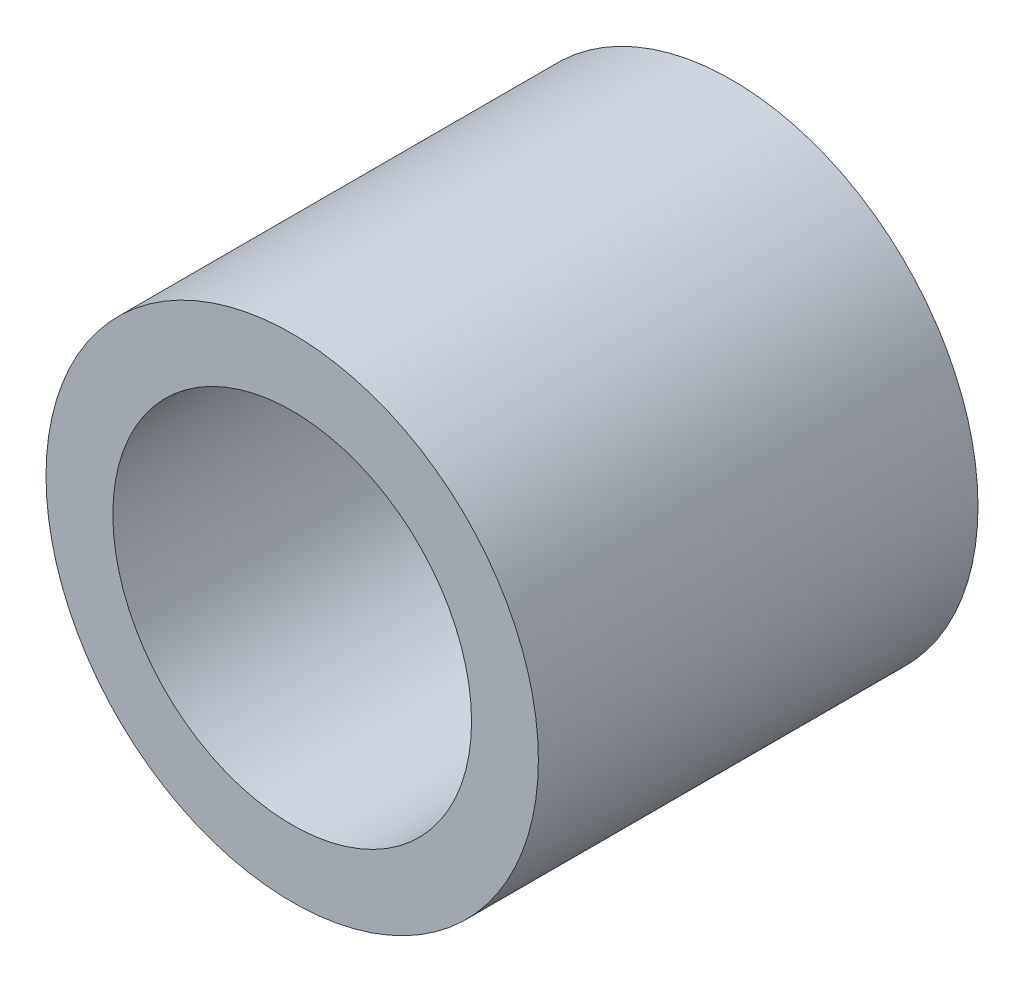
from build123d import *

# Parameters (mm, degrees)
SKETCH_1_R      = 14
SKETCH_1_R_2    = 10.2
EXTRUDE_1_DEPTH = 25


with BuildPart() as part:
    # 草图1 → 凸台-拉伸1 (new body)
    with BuildSketch(Plane.XY):
        Circle(SKETCH_1_R)
        Circle(SKETCH_1_R_2, mode=Mode.SUBTRACT)
    extrude(amount=EXTRUDE_1_DEPTH)


solid = part.part
